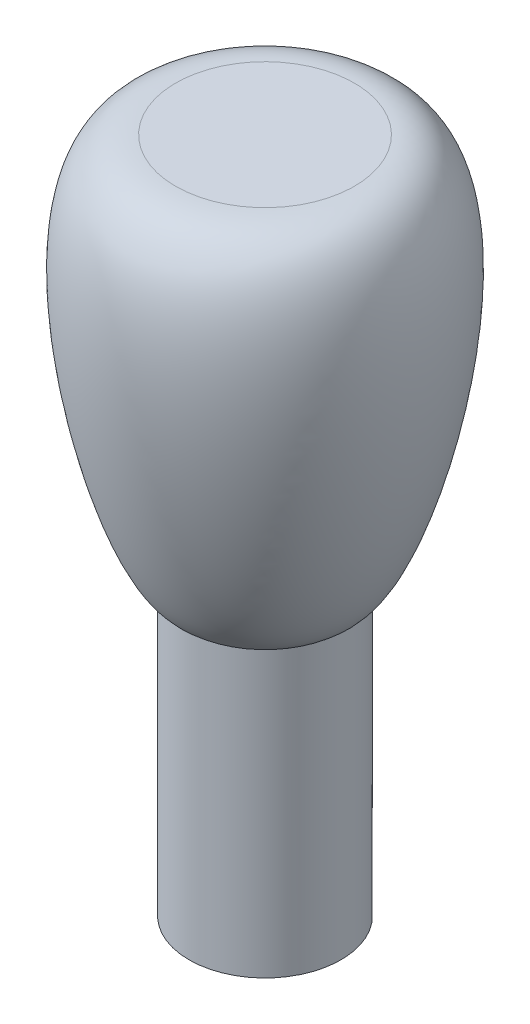
from build123d import *

# Parameters (mm, degrees)
SKETCH1_W          = 2.4
SKETCH1_H          = 9
CUT_EXTRUDE1_DEPTH = 3


with BuildPart() as part:
    # Sketch1 → Revolve1 (revolve)
    with BuildSketch(Plane.XY):
        with Locations((1.2, 4.5)):
            Rectangle(SKETCH1_W, SKETCH1_H)
        with BuildLine():
            Line((0, 9), (2.4, 9))
            add(Edge.make_bspline(
                [(2.4, 9), (3.943624144, 9.640112892), (6.678218712, 21.005740033), (2.23867002, 21.461291421), (0.753276849, 21.008863183), (0, 21.376813595)],
                knots=[0, 0, 0, 0, 0.773199914, 0.826737294, 1, 1, 1, 1], degree=3))
            Line((0, 21.376813595), (0, 9))
        make_face()
        with BuildLine():
            Line((2.824829573, 21.376813595), (0, 21.376813595))
            add(Edge.make_bspline(
                [(2.824829573, 21.376813595), (2.798017085, 21.376813595), (1.92435926, 21.365557129), (0.753276849, 21.008863183), (0, 21.376813595)],
                knots=[0.821191051, 0.821191051, 0.821191051, 0.821191051, 0.826737294, 1, 1, 1, 1], degree=3))
        make_face()
    revolve(axis=Axis((0, 21.376813595, 0), (0, -1, 0)))

    # Sketch2 → Cut-Extrude1 (cut)
    with BuildSketch(Plane.XZ):
        with BuildLine():
            Line((-1.8734994, -1.5), (1.8734994, -1.5))
            ThreePointArc((1.8734994, -1.5), (0, -2.4), (-1.8734994, -1.5))
        make_face()
    extrude(amount=-CUT_EXTRUDE1_DEPTH, mode=Mode.SUBTRACT)


solid = part.part
